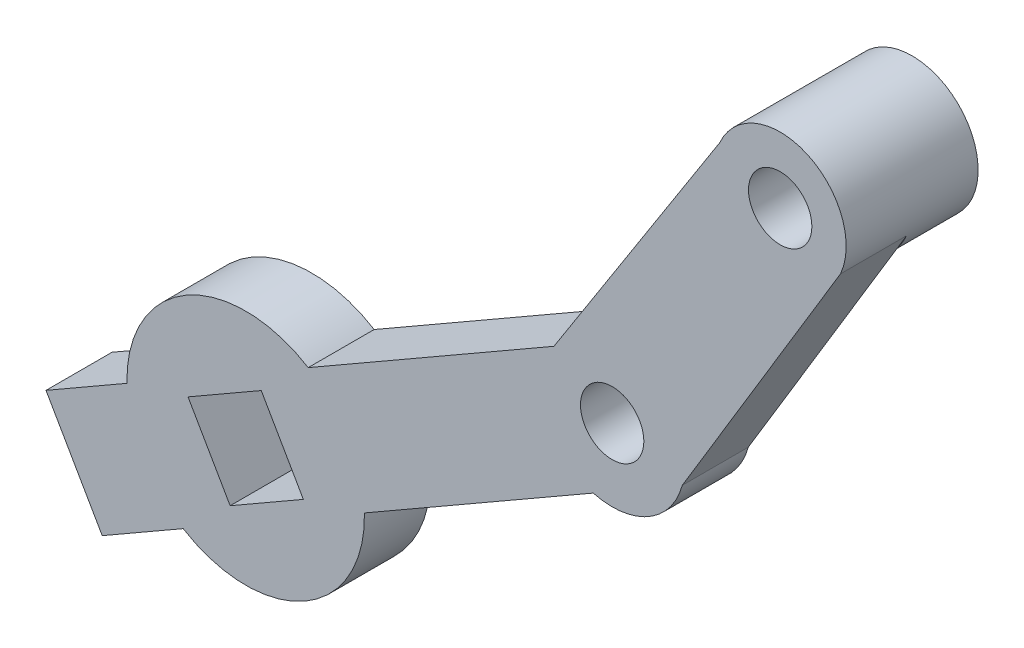
from build123d import *

# Parameters (mm, degrees)
BOSS_EXTRUDE1_DEPTH = 5
SKETCH8_R           = 9
BOSS_EXTRUDE3_DEPTH = 5
CUT_EXTRUDE1_REACH  = 53.228
SKETCH12_R          = 1
CUT_EXTRUDE2_DEPTH  = 0.5
SKETCH13_R          = 5
BOSS_EXTRUDE5_DEPTH = 5
CUT_EXTRUDE3_REACH  = 53.955
SKETCH15_R          = 2.4
CUT_EXTRUDE4_REACH  = 53.228
SKETCH16_R          = 2.4


with BuildPart() as part:
    # Sketch1 → Boss-Extrude1 (new body)
    with BuildSketch(Plane(origin=(0, 0, 0), x_dir=(0.4985289035363021, -0.866873077410351, 0), z_dir=(0, 0, 1))):
        with BuildLine():
            ThreePointArc((8.899126574, -3.909046337), (10.510039278, -0.019959041), (8.899126574, 3.869128256))
            Line((8.899126574, 3.869128256), (-2.35642803, 24.179978159))
            ThreePointArc((-2.35642803, 24.179978159), (-9.345167797, 25.255857552), (-10.421047189, 18.267117784))
            Line((-10.421047189, 18.267117784), (0.353553391, -2.434608777))
            Line((0.353553391, -2.434608777), (0.353553391, -46.838046337))
            Line((0.353553391, -46.838046337), (8.899126574, -46.838046337))
            Line((8.899126574, -46.838046337), (8.899126574, -3.909046337))
        make_face()
    extrude(amount=BOSS_EXTRUDE1_DEPTH)

    # Sketch8 → Boss-Extrude3 (add)
    with BuildSketch(Plane(origin=(0, 0, 0), x_dir=(-1, 0, 0), z_dir=(0, 0, -1))):
        with Locations((25.293181008, -19.882635909)):
            Circle(SKETCH8_R)
    extrude(amount=-BOSS_EXTRUDE3_DEPTH)

    # Sketch11 → Cut-Extrude1 (cut, up to next)
    with BuildSketch(Plane(origin=(0, 0, 0), x_dir=(-1, 0, 0), z_dir=(0, 0, -1)), mode=Mode.PRIVATE) as cut_extrude1_sk1:
        Polygon((26.471882365, -24.251922248), (29.662467347, -18.703934553), (24.114479652, -15.51334957), (20.923894669, -21.061337265), align=None)
    cut_extrude1_tool1 = extrude(cut_extrude1_sk1.sketch, amount=-CUT_EXTRUDE1_REACH, mode=Mode.PRIVATE) & part.part
    add(cut_extrude1_tool1.solids().sort_by_distance((-25.293181, -19.882636, 0))[0], mode=Mode.SUBTRACT)

    # Sketch12 → Cut-Extrude2 (cut)
    with BuildSketch(Plane(origin=(-24.825551359, -14.27689384, 0), x_dir=(0, 0, 1), z_dir=(-0.866873077410351, -0.49852890353630236, 0))):
        with Locations(Location((2.5, -4.626339983, 0), (0, 0, 270))):
            Circle(SKETCH12_R)
    extrude(amount=-CUT_EXTRUDE2_DEPTH, mode=Mode.SUBTRACT)

    # Sketch13 → Boss-Extrude5 (add)
    with BuildSketch(Plane(origin=(0, 0, 0), x_dir=(-1, 0, 0), z_dir=(0, 0, -1))):
        with Locations((-15.213151988, 16.118776732)):
            Circle(SKETCH13_R)
    extrude(amount=BOSS_EXTRUDE5_DEPTH)

    # Sketch15 → Cut-Extrude3 (cut, up to next)
    with BuildSketch(Plane(origin=(0, 0, -5), x_dir=(-1, 0, 0), z_dir=(0, 0, -1)), mode=Mode.PRIVATE) as cut_extrude3_sk1:
        with Locations((-15.213151988, 16.118776732)):
            Circle(SKETCH15_R)
    cut_extrude3_tool1 = extrude(cut_extrude3_sk1.sketch, amount=-CUT_EXTRUDE3_REACH, mode=Mode.PRIVATE) & part.part
    add(cut_extrude3_tool1.solids().sort_by_distance((15.213152, 16.118777, -5))[0], mode=Mode.SUBTRACT)

    # Sketch16 → Cut-Extrude4 (cut, up to next)
    with BuildSketch(Plane(origin=(0, 0, 0), x_dir=(-1, 0, 0), z_dir=(0, 0, -1)), mode=Mode.PRIVATE) as cut_extrude4_sk1:
        with Locations((-2.480347433, -4.353018325)):
            Circle(SKETCH16_R)
    cut_extrude4_tool1 = extrude(cut_extrude4_sk1.sketch, amount=-CUT_EXTRUDE4_REACH, mode=Mode.PRIVATE) & part.part
    add(cut_extrude4_tool1.solids().sort_by_distance((2.480347, -4.353018, 0))[0], mode=Mode.SUBTRACT)


solid = part.part
